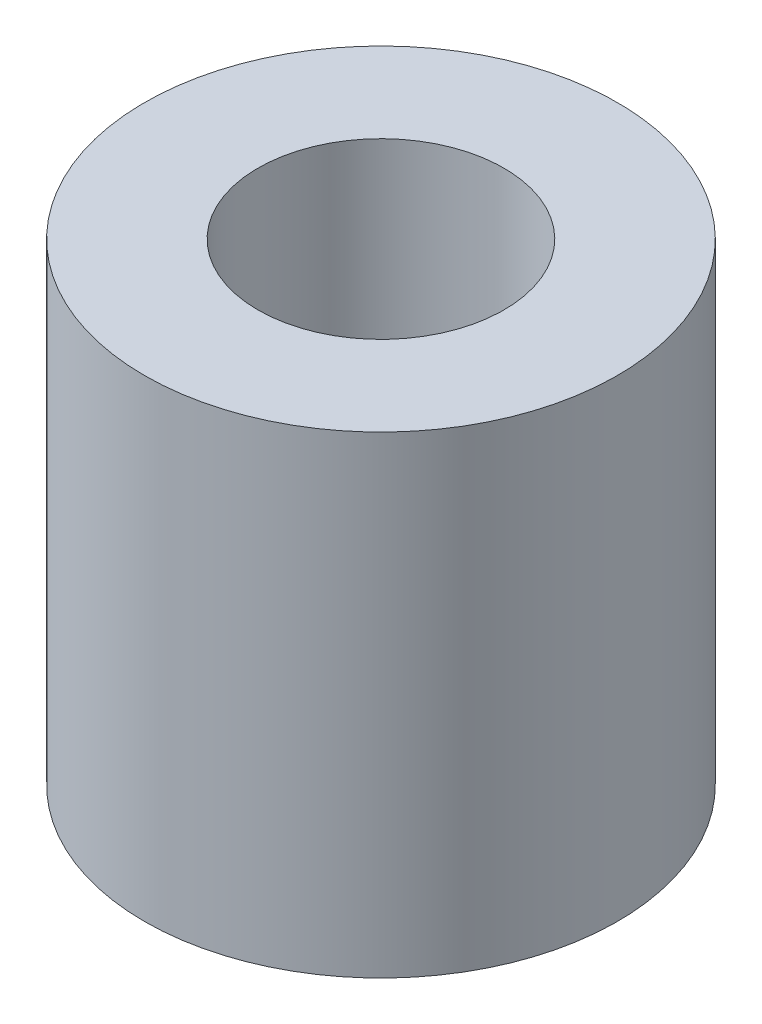
from build123d import *

# Parameters (mm, degrees)
SKETCH1_R           = 5
SKETCH1_R_2         = 2.6
BOSS_EXTRUDE1_DEPTH = 10


with BuildPart() as part:
    # Sketch1 → Boss-Extrude1 (new body)
    with BuildSketch(Plane(origin=(0, 0, 0), x_dir=(1, 0, 0), z_dir=(0, 1, 0))):
        Circle(SKETCH1_R)
        Circle(SKETCH1_R_2, mode=Mode.SUBTRACT)
    extrude(amount=BOSS_EXTRUDE1_DEPTH)


solid = part.part
